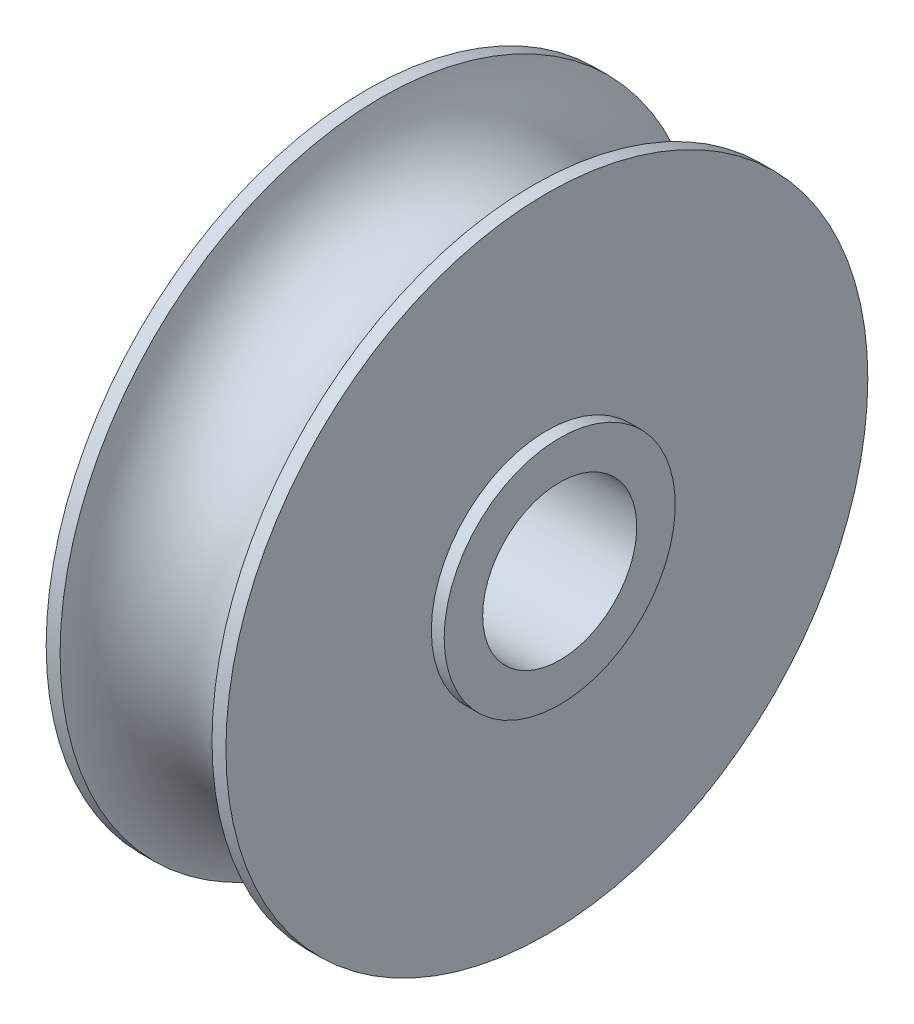
from build123d import *


with BuildPart() as part:
    # Esquisse1 → Révolution1 (revolve)
    with BuildSketch(Plane.XY):
        with BuildLine():
            Line((2.958039892, 12.5), (3.5, 12.5))
            Line((3.5, 12.5), (3.5, 4.5))
            Line((3.5, 4.5), (4, 4.5))
            Line((4, 4.5), (4, 3))
            Line((4, 3), (-4, 3))
            Line((-4, 3), (-4, 4.5))
            Line((-4, 4.5), (-3.5, 4.5))
            Line((-3.5, 4.5), (-3.5, 12.5))
            Line((-3.5, 12.5), (-2.958039892, 12.5))
            ThreePointArc((-2.958039892, 12.5), (0, 10), (2.958039892, 12.5))
        make_face()
    revolve(axis=Axis((-29.079829172, 0, 0), (1, 0, 0)))


solid = part.part
